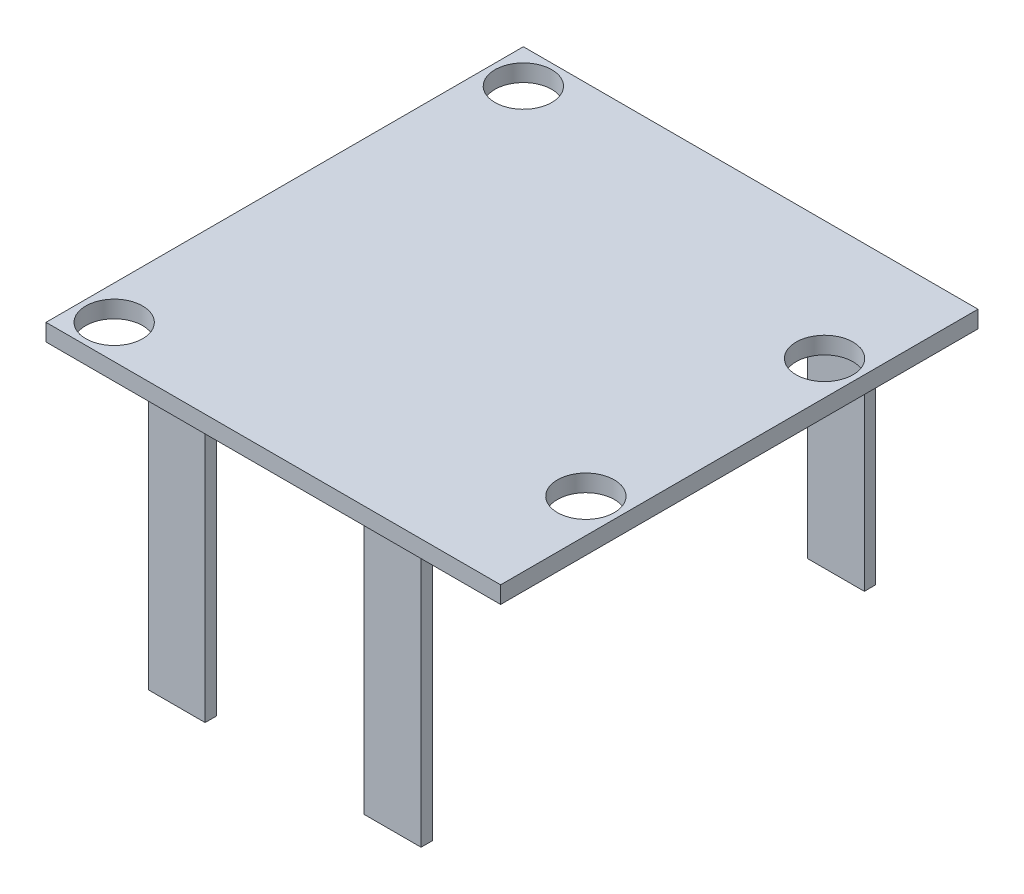
from build123d import *

# Parameters (mm, degrees)
SKETCH1_W           = 400
SKETCH1_H           = 420
BOSS_EXTRUDE1_DEPTH = 15
SKETCH2_R           = 25
CUT_EXTRUDE1_DEPTH  = 15
SKETCH3_W           = 50
SKETCH3_H           = 10
BOSS_EXTRUDE2_DEPTH = 230


with BuildPart() as part:
    # Sketch1 → Boss-Extrude1 (new body)
    with BuildSketch(Plane(origin=(0, 0, 0), x_dir=(1, 0, 0), z_dir=(0, 1, 0))):
        Rectangle(SKETCH1_W, SKETCH1_H)
    extrude(amount=BOSS_EXTRUDE1_DEPTH)

    # Sketch2 → Cut-Extrude1 (cut)
    with BuildSketch(Plane(origin=(0, 15, 0), x_dir=(1, 0, 0), z_dir=(0, 1, 0))):
        with Locations((-170, 180)):
            Circle(SKETCH2_R)
        with Locations((-170, -180)):
            Circle(SKETCH2_R)
        with Locations((170, -105)):
            Circle(SKETCH2_R)
        with Locations((170, 105)):
            Circle(SKETCH2_R)
    extrude(amount=-CUT_EXTRUDE1_DEPTH, mode=Mode.SUBTRACT)

    # Sketch3 → Boss-Extrude2 (add)
    with BuildSketch(Plane.XZ):
        with Locations((-95, 195)):
            Rectangle(SKETCH3_W, SKETCH3_H)
        with Locations((95, 195)):
            Rectangle(SKETCH3_W, SKETCH3_H)
        with Locations((-95, -195)):
            Rectangle(SKETCH3_W, SKETCH3_H)
        with Locations((95, -195)):
            Rectangle(SKETCH3_W, SKETCH3_H)
    extrude(amount=BOSS_EXTRUDE2_DEPTH)


solid = part.part
